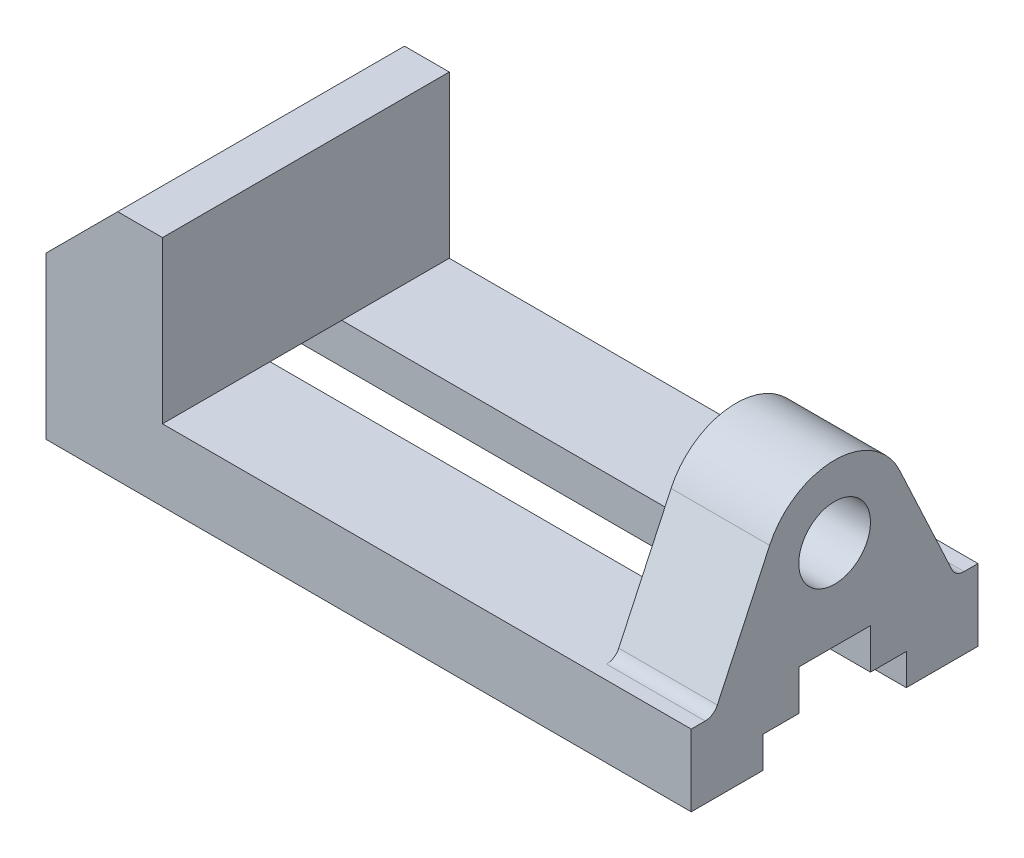
from build123d import *

# Parameters (mm, degrees)
BOSS_EXTRUDE1_DEPTH  = 32
SKETCH3_R            = 8
BOSS_EXTRUDE2_DEPTH  = 22
CUT_EXTRUDE1_DEPTH   = 145
LPATTERN1_COUNT      = 2
LPATTERN1_PITCH      = 70
LPATTERN1_COUNT_DIR2 = 2
LPATTERN1_PITCH_DIR2 = 44


with BuildPart() as part:
    # Sketch1 → Boss-Extrude1 (new body, symmetric)
    with BuildSketch(Plane.XY):
        Polygon((0, 0), (0, 36), (16, 52), (26, 52), (26, 16), (144, 16), (144, 0), align=None)
    extrude(amount=BOSS_EXTRUDE1_DEPTH, both=True)

    # Sketch3 → Boss-Extrude2 (add)
    with BuildSketch(Plane(origin=(144, 0, 0), x_dir=(0, 0, -1), z_dir=(1, 0, 0))):
        with BuildLine():
            Line((-14.500924593, 42.761892188), (-26.172487288, 17.732145215))
            ThreePointArc((-26.172487288, 17.732145215), (-27.279511824, 16.469825663), (-28.891410649, 16))
            Line((-28.891410649, 16), (28.891410649, 16))
            ThreePointArc((28.891410649, 16), (27.279511824, 16.469825663), (26.172487288, 17.732145215))
            Line((26.172487288, 17.732145215), (14.500924593, 42.761892188))
            ThreePointArc((14.500924593, 42.761892188), (0, 52), (-14.500924593, 42.761892188))
        make_face()
        with Locations((0, 36)):
            Circle(SKETCH3_R, mode=Mode.SUBTRACT)
    extrude(amount=-BOSS_EXTRUDE2_DEPTH)

    # Sketch4 → Cut-Extrude1 (cut, through all)
    with BuildSketch(Plane(origin=(144, 0, 0), x_dir=(0, 0, -1), z_dir=(1, 0, 0))):
        Polygon((-16, 0), (16, 0), (16, 7), (8, 7), (8, 16), (-8, 16), (-8, 7), (-16, 7), align=None)
    extrude(amount=-CUT_EXTRUDE1_DEPTH, mode=Mode.SUBTRACT)

    # Sketch6 → Ø6.0mm Dowel Hole1 (revolve, cut)
    with BuildSketch(Plane(origin=(38, 0, 22), x_dir=(0, 0, -1), z_dir=(1, 0, 0))):
        Polygon((0, 0), (0, 11.802581857), (3, 10), (3, 0), align=None)
    f_6_0mm_dowel_hole1 = revolve(axis=Axis((38, -6.35, 22), (0, 1, 0)), mode=Mode.SUBTRACT)

    # LPattern1: 6.0mm Dowel Hole1 2 × 2
    with Locations(*[(i * LPATTERN1_PITCH, 0, -j * LPATTERN1_PITCH_DIR2) for i in range(LPATTERN1_COUNT) for j in range(LPATTERN1_COUNT_DIR2) if (i, j) != (0, 0)]):
        add(f_6_0mm_dowel_hole1, mode=Mode.SUBTRACT)


solid = part.part
